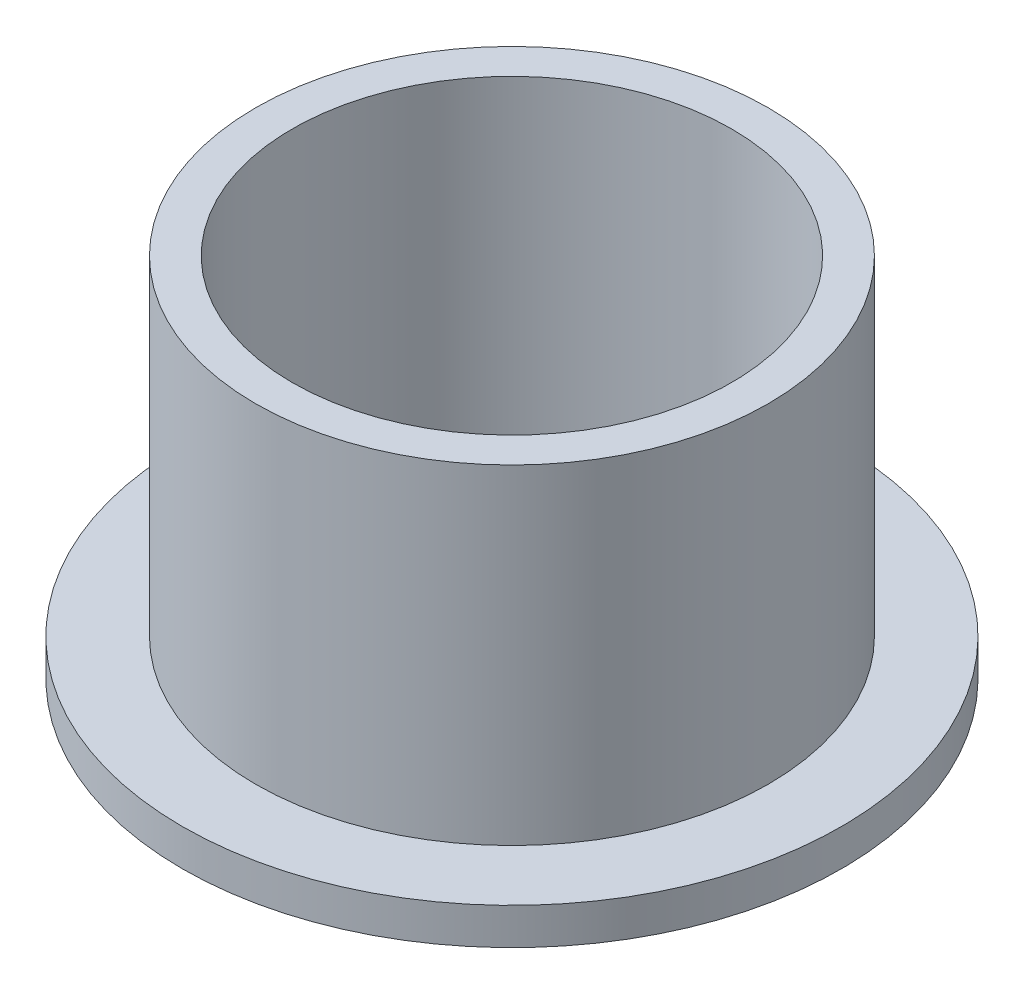
from build123d import *

# Parameters (mm, degrees)
SKETCH2_R           = 7
SKETCH2_R_2         = 6
BOSS_EXTRUDE1_DEPTH = 10
SKETCH3_R           = 9
SKETCH3_R_2         = 7
BOSS_EXTRUDE2_DEPTH = 1


with BuildPart() as part:
    # Sketch2 → Boss-Extrude1 (new body)
    with BuildSketch(Plane(origin=(0, 0, 0), x_dir=(1, 0, 0), z_dir=(0, 1, 0))):
        Circle(SKETCH2_R)
        Circle(SKETCH2_R_2, mode=Mode.SUBTRACT)
    extrude(amount=BOSS_EXTRUDE1_DEPTH)

    # Sketch3 → Boss-Extrude2 (add)
    with BuildSketch(Plane(origin=(0, 0, 0), x_dir=(1, 0, 0), z_dir=(0, 1, 0))):
        Circle(SKETCH3_R)
        Circle(SKETCH3_R_2, mode=Mode.SUBTRACT)
    extrude(amount=BOSS_EXTRUDE2_DEPTH)


solid = part.part
